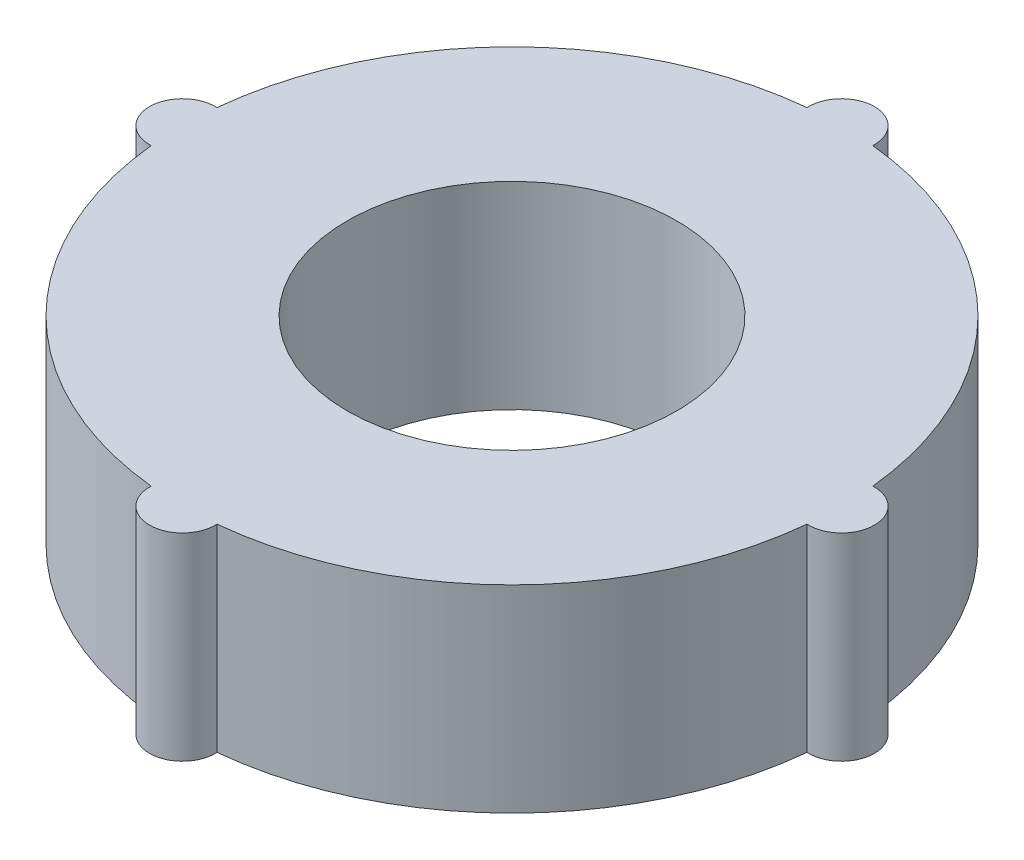
from build123d import *

# Parameters (mm, degrees)
CROQUIS1_R              = 25
SALIENTE_EXTRUIR1_DEPTH = 30


with BuildPart() as part:
    # Croquis1 → Saliente-Extruir1 (new body)
    with BuildSketch(Plane(origin=(0, 0, 0), x_dir=(1, 0, 0), z_dir=(0, 1, 0))):
        with BuildLine():
            ThreePointArc((-4.993746089, 49.75), (-35.355339059, 35.355339059), (-49.75, 4.993746089))
            ThreePointArc((-49.75, 4.993746089), (-55, 0), (-49.75, -4.993746089))
            ThreePointArc((-49.75, -4.993746089), (-35.355339059, -35.355339059), (-4.993746089, -49.75))
            ThreePointArc((-4.993746089, -49.75), (0, -55), (4.993746089, -49.75))
            ThreePointArc((4.993746089, -49.75), (35.355339059, -35.355339059), (49.75, -4.993746089))
            ThreePointArc((49.75, -4.993746089), (55, 0), (49.75, 4.993746089))
            ThreePointArc((49.75, 4.993746089), (35.355339059, 35.355339059), (4.993746089, 49.75))
            ThreePointArc((4.993746089, 49.75), (0, 55), (-4.993746089, 49.75))
        make_face()
        with Locations(Location((0, 0, 0), (0, 0, 270))):  # turned: the seam where the file's is
            Circle(CROQUIS1_R, mode=Mode.SUBTRACT)
    extrude(amount=SALIENTE_EXTRUIR1_DEPTH)


solid = part.part
